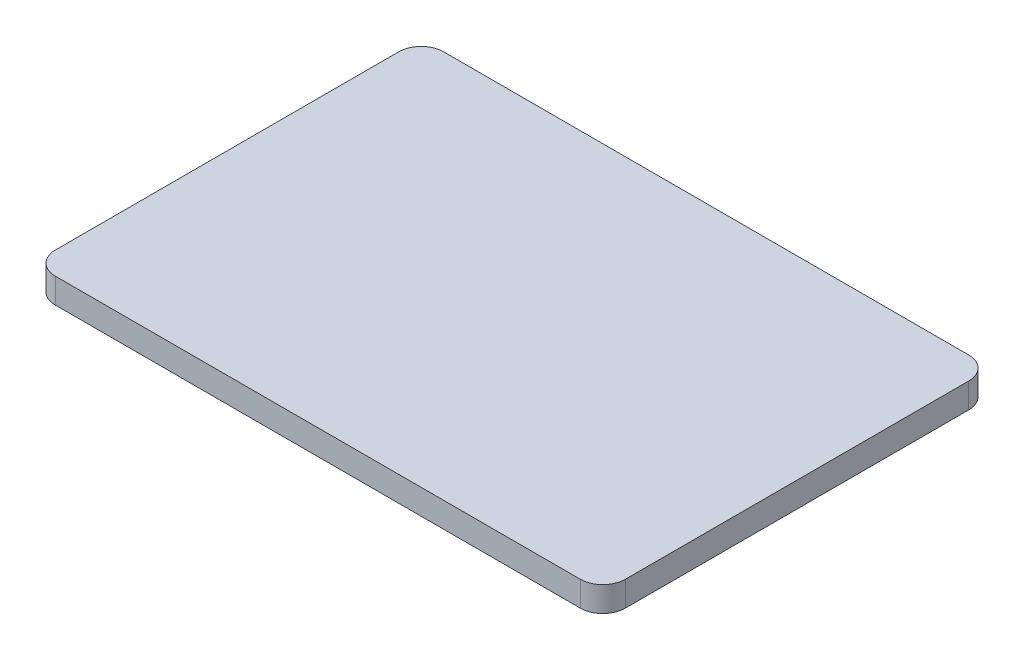
from build123d import *

# Parameters (mm, degrees)
EXTRUDE_1_DEPTH = 2


with BuildPart() as part:
    # 草图1 → 凸台-拉伸1 (new body)
    with BuildSketch(Plane(origin=(0, 0, 0), x_dir=(1, 0, 0), z_dir=(0, 1, 0))):
        with BuildLine():
            Line((-20.95, 15.5), (20.95, 15.5))
            ThreePointArc((20.95, 15.5), (22.222792206, 14.972792206), (22.75, 13.7))
            Line((22.75, 13.7), (22.75, -13.7))
            ThreePointArc((22.75, -13.7), (22.222792206, -14.972792206), (20.95, -15.5))
            Line((20.95, -15.5), (-20.95, -15.5))
            ThreePointArc((-20.95, -15.5), (-22.222792206, -14.972792206), (-22.75, -13.7))
            Line((-22.75, -13.7), (-22.75, 13.7))
            ThreePointArc((-22.75, 13.7), (-22.222792206, 14.972792206), (-20.95, 15.5))
        make_face()
    extrude(amount=EXTRUDE_1_DEPTH)


solid = part.part
